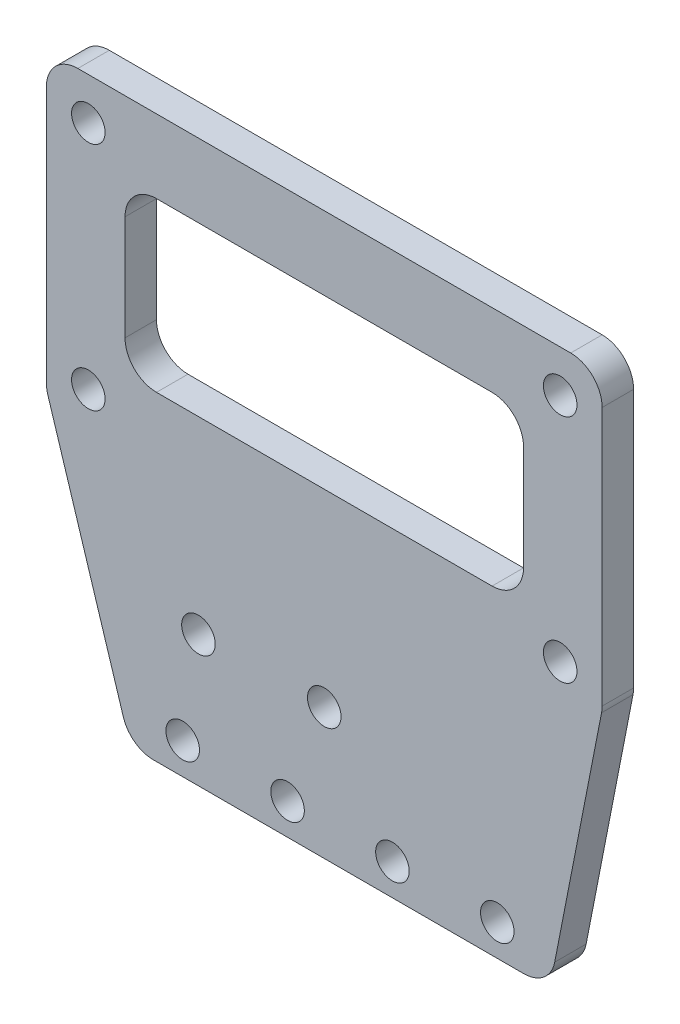
from build123d import *

# Parameters (mm, degrees)
SKETCH_1_R          = 1.6
EXTRUDE_1_DEPTH     = 3
SKETCH_2_R          = 1.6
CUT_EXTRUDE_1_DEPTH = 4
FILLET_1_R          = 3
SKETCH_4_R          = 1.6
CUT_EXTRUDE_2_DEPTH = 4
SKETCH_5_W          = 38
SKETCH_5_H          = 16
CUT_EXTRUDE_3_DEPTH = 4
FILLET_2_R          = 3


with BuildPart() as part:
    # 草图1 → 凸台-拉伸1 (new body)
    with BuildSketch(Plane.XY):
        Polygon((-40, 0), (-48, 25.544444444), (-48, 53.5), (5, 53.5), (5, 25.544444444), (0, 0), align=None)
        with Locations((-44, 49.5)):
            Circle(SKETCH_1_R, mode=Mode.SUBTRACT)
        with Locations((1, 49.5)):
            Circle(SKETCH_1_R, mode=Mode.SUBTRACT)
        with Locations((1, 27.5)):
            Circle(SKETCH_1_R, mode=Mode.SUBTRACT)
        with Locations((-44, 27.5)):
            Circle(SKETCH_1_R, mode=Mode.SUBTRACT)
    extrude(amount=EXTRUDE_1_DEPTH)

    # 草图2 → 切除-拉伸1 (cut, through all)
    with BuildSketch(Plane.XY.offset(3)):
        with Locations((-5, 3)):
            Circle(SKETCH_2_R)
        with Locations((-15, 3)):
            Circle(SKETCH_2_R)
        with Locations((-25, 3)):
            Circle(SKETCH_2_R)
        with Locations((-35, 3)):
            Circle(SKETCH_2_R)
    extrude(amount=-CUT_EXTRUDE_1_DEPTH, mode=Mode.SUBTRACT)

    # 圆角1
    fillet_1_edges = [part.edges().sort_by_distance(p)[0] for p in [
        (0, 0, 1.5),
        (-40, 0, 1.5),
        (-48, 25.544444444, 1.5),
        (-48, 53.5, 1.5),
        (5, 53.5, 1.5),
        (5, 25.544444444, 1.5),
    ]]
    fillet(fillet_1_edges, radius=FILLET_1_R)

    # 草图4 → 切除-拉伸2 (cut, through all)
    with BuildSketch(Plane.XY.offset(3)):
        with Locations((-21.5, 36.5)):
            Circle(SKETCH_4_R)
        with Locations((-33.5, 12.5)):
            Circle(SKETCH_4_R)
        with Locations((-21.5, 12.5)):
            Circle(SKETCH_4_R)
    extrude(amount=-CUT_EXTRUDE_2_DEPTH, mode=Mode.SUBTRACT)

    # 草图5 → 切除-拉伸3 (cut, through all)
    with BuildSketch(Plane(origin=(0, 0, 0), x_dir=(-1, 0, 0), z_dir=(0, 0, -1))):
        with Locations((21.5, 38.5)):
            Rectangle(SKETCH_5_W, SKETCH_5_H)
    extrude(amount=-CUT_EXTRUDE_3_DEPTH, mode=Mode.SUBTRACT)

    # 圆角2
    fillet_2_edges = [part.edges().sort_by_distance(p)[0] for p in [
        (-40.5, 46.5, 1.5),
        (-40.5, 30.5, 1.5),
        (-2.5, 30.5, 1.5),
        (-2.5, 46.5, 1.5),
    ]]
    fillet(fillet_2_edges, radius=FILLET_2_R)


solid = part.part
